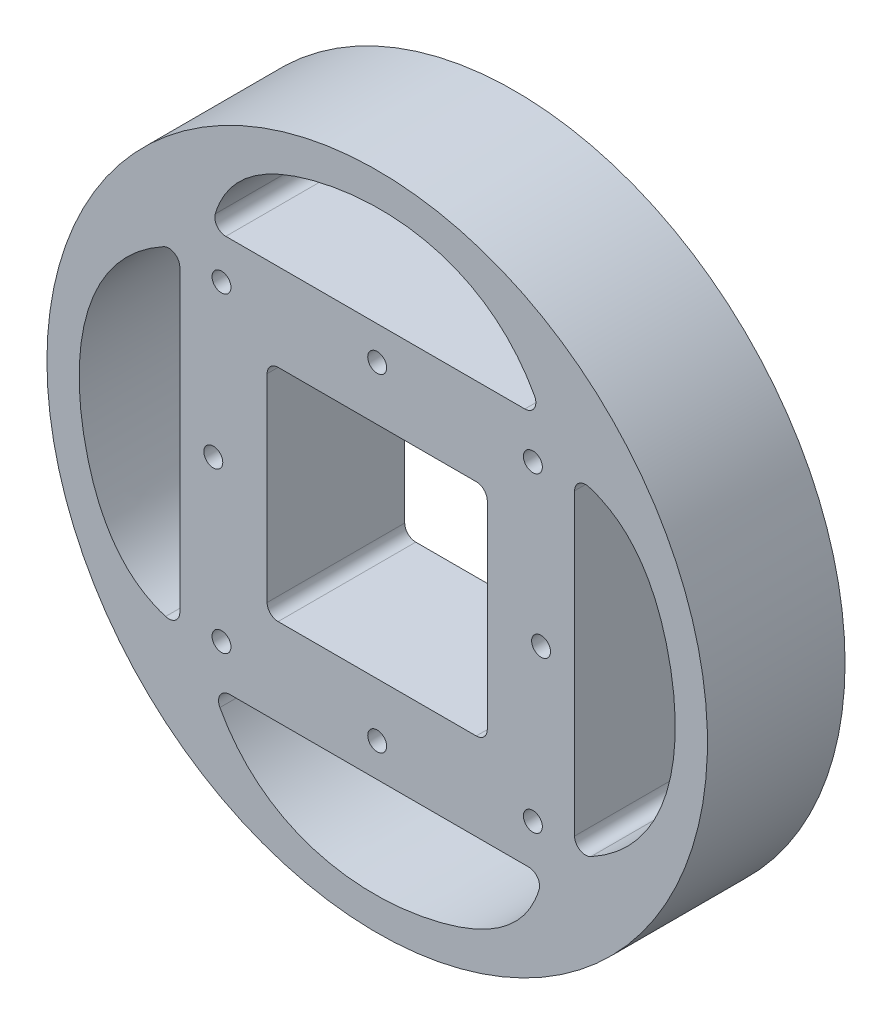
from build123d import *

# Parameters (mm, degrees)
SKETCH1_R                = 76.2
SKETCH1_R_2              = 69.85
BOSS_EXTRUDE1_DEPTH      = 107.95
SKETCH3_R                = 76.2
BOSS_EXTRUDE2_DEPTH      = 6.35
BOSS_EXTRUDE2_DEPTH_BACK = 31.75
SKETCH5_R                = 2.1828125
CUT_EXTRUDE2_DEPTH       = 39.1
SKETCH11_R               = 2.1828125
CUT_EXTRUDE11_DEPTH      = 39.1
SKETCH4_3_W              = 38.1
SKETCH4_3_H              = 38.1
BOSS_EXTRUDE3_DEPTH      = 19.05
CUT_EXTRUDE12_START      = -31.75
SKETCH12_R               = 69.85
CUT_EXTRUDE12_DEPTH      = 25.4
SKETCH13_R               = 76.2
CUT_EXTRUDE13_DEPTH      = 108.95
SKETCH14_W               = 50.8
SKETCH14_H               = 50.8
CUT_EXTRUDE14_DEPTH      = 32.75
CUT_EXTRUDE15_DEPTH      = 32.75
FILLET2_R                = 2.54


with BuildPart() as part:
    # Sketch1 → Boss-Extrude1 (new body)
    with BuildSketch(Plane.XY):
        Circle(SKETCH1_R)
        Circle(SKETCH1_R_2, mode=Mode.SUBTRACT)
    extrude(amount=BOSS_EXTRUDE1_DEPTH)

    # Sketch3 → Boss-Extrude2 (add, two sides)
    with BuildSketch(Plane.XY) as boss_extrude2_sk:
        Circle(SKETCH3_R)
    extrude(amount=BOSS_EXTRUDE2_DEPTH)
    extrude(boss_extrude2_sk.sketch, amount=-BOSS_EXTRUDE2_DEPTH_BACK)

    # Sketch5 → Cut-Extrude2 (cut, through all)
    with BuildSketch(Plane.XY.offset(6.35)):
        with Locations((0, 37.81298)):
            Circle(SKETCH5_R)
        with Locations((37.81298, 0)):
            Circle(SKETCH5_R)
        with Locations((-37.81298, 0)):
            Circle(SKETCH5_R)
        with Locations((0, -37.81298)):
            Circle(SKETCH5_R)
    extrude(amount=-CUT_EXTRUDE2_DEPTH, mode=Mode.SUBTRACT)

    # Sketch11 → Cut-Extrude11 (cut, through all)
    with BuildSketch(Plane.XY.offset(6.35)):
        with Locations((-35.921024484, 35.921024484)):
            Circle(SKETCH11_R)
        with Locations((-35.921024484, -35.921024484)):
            Circle(SKETCH11_R)
        with Locations((35.921024484, -35.921024484)):
            Circle(SKETCH11_R)
        with Locations((35.921024484, 35.921024484)):
            Circle(SKETCH11_R)
    extrude(amount=-CUT_EXTRUDE11_DEPTH, mode=Mode.SUBTRACT)

    # Sketch4_3 → Boss-Extrude3 (add)
    with BuildSketch(Plane.XY.offset(6.35)):
        Rectangle(SKETCH4_3_W, SKETCH4_3_H)
    extrude(amount=BOSS_EXTRUDE3_DEPTH)

    # Sketch12 → Cut-Extrude12 (cut)
    with BuildSketch(Plane(origin=(0, 0, -31.75), x_dir=(-1, 0, 0), z_dir=(0, 0, -1)).offset(CUT_EXTRUDE12_START)):
        Circle(SKETCH12_R)
    extrude(amount=-CUT_EXTRUDE12_DEPTH, mode=Mode.SUBTRACT)

    # Sketch13 → Cut-Extrude13 (cut, through all)
    with BuildSketch(Plane(origin=(0, 0, 0), x_dir=(-1, 0, 0), z_dir=(0, 0, -1))):
        Circle(SKETCH13_R)
    extrude(amount=-CUT_EXTRUDE13_DEPTH, mode=Mode.SUBTRACT)

    # Sketch14 → Cut-Extrude14 (cut, through all)
    with BuildSketch(Plane.XY):
        Rectangle(SKETCH14_W, SKETCH14_H)
    extrude(amount=-CUT_EXTRUDE14_DEPTH, mode=Mode.SUBTRACT)

    # Sketch15 → Cut-Extrude15 (cut, through all)
    with BuildSketch(Plane.XY):
        with BuildLine():
            Line((-38.1, -45.540313254), (38.1, -45.540313254))
            add(Edge.make_bspline(
                [(-38.1, -45.540313254), (-29.021224269, -67.0386022), (5.839811174, -74.537239213), (36.070359943, -58.589701768), (38.1, -45.540313254)],
                knots=[0, 0, 0, 0, 0.631803997, 1, 1, 1, 1], degree=3))
        make_face()
        with BuildLine():
            Line((-45.540313254, 38.1), (-45.540313254, -38.1))
            add(Edge.make_bspline(
                [(-45.540313254, 38.1), (-67.0386022, 29.021224269), (-74.537239213, -5.839811174), (-58.589701768, -36.070359943), (-45.540313254, -38.1)],
                knots=[0, 0, 0, 0, 0.631803997, 1, 1, 1, 1], degree=3))
        make_face()
        with BuildLine():
            Line((38.1, 45.540313254), (-38.1, 45.540313254))
            add(Edge.make_bspline(
                [(38.1, 45.540313254), (29.021224269, 67.0386022), (-5.839811174, 74.537239213), (-36.070359943, 58.589701768), (-38.1, 45.540313254)],
                knots=[0, 0, 0, 0, 0.631803997, 1, 1, 1, 1], degree=3))
        make_face()
        with BuildLine():
            Line((45.540313254, -38.1), (45.540313254, 38.1))
            add(Edge.make_bspline(
                [(45.540313254, -38.1), (67.0386022, -29.021224269), (74.537239213, 5.839811174), (58.589701768, 36.070359943), (45.540313254, 38.1)],
                knots=[0, 0, 0, 0, 0.631803997, 1, 1, 1, 1], degree=3))
        make_face()
    extrude(amount=-CUT_EXTRUDE15_DEPTH, mode=Mode.SUBTRACT)

    # Fillet2
    fillet2_edges = [part.edges().sort_by_distance(p)[0] for p in [
        (45.540313254, 38.1, -15.875),
        (45.540313254, -38.1, -15.875),
        (38.1, 45.540313254, -15.875),
        (-38.1, 45.540313254, -15.875),
        (25.4, 25.4, -15.875),
        (25.4, -25.4, -15.875),
        (-25.4, -25.4, -15.875),
        (-25.4, 25.4, -15.875),
        (-45.540313254, 38.1, -15.875),
        (-45.540313254, -38.1, -15.875),
        (-38.1, -45.540313254, -15.875),
        (38.1, -45.540313254, -15.875),
    ]]
    fillet(fillet2_edges, radius=FILLET2_R)


solid = part.part
